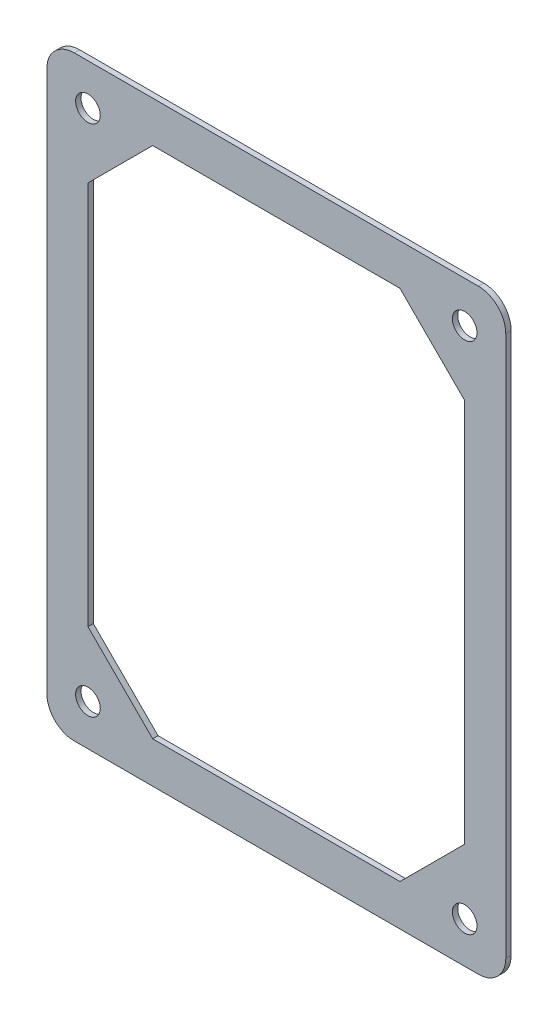
from build123d import *

# Parameters (mm, degrees)
SKETCH1_R           = 2.286
BOSS_EXTRUDE1_DEPTH = 1


with BuildPart() as part:
    # Sketch1 → Boss-Extrude1 (new body)
    with BuildSketch(Plane.XY):
        with BuildLine():
            Line((1.27, -104.14), (1.27, -3.81))
            ThreePointArc((1.27, -3.81), (-0.217897552, -0.217897552), (-3.81, 1.27))
            Line((-3.81, 1.27), (-78.74, 1.27))
            ThreePointArc((-78.74, 1.27), (-82.332102448, -0.217897552), (-83.82, -3.81))
            Line((-83.82, -3.81), (-83.82, -104.14))
            ThreePointArc((-83.82, -104.14), (-82.332102448, -107.732102448), (-78.74, -109.22))
            Line((-78.74, -109.22), (-3.81, -109.22))
            ThreePointArc((-3.81, -109.22), (-0.217897552, -107.732102448), (1.27, -104.14))
        make_face()
        with Locations((-76.2, -6.35)):
            Circle(SKETCH1_R, mode=Mode.SUBTRACT)
        with Locations((-76.2, -101.6)):
            Circle(SKETCH1_R, mode=Mode.SUBTRACT)
        with Locations((-6.35, -101.6)):
            Circle(SKETCH1_R, mode=Mode.SUBTRACT)
        with Locations((-6.35, -6.35)):
            Circle(SKETCH1_R, mode=Mode.SUBTRACT)
        Polygon((-76.2, -18.35), (-64.2, -6.35), (-18.35, -6.35), (-6.35, -18.35), (-6.35, -89.6), (-18.35, -101.6), (-64.2, -101.6), (-76.2, -89.6), align=None, mode=Mode.SUBTRACT)
    extrude(amount=BOSS_EXTRUDE1_DEPTH)


solid = part.part
